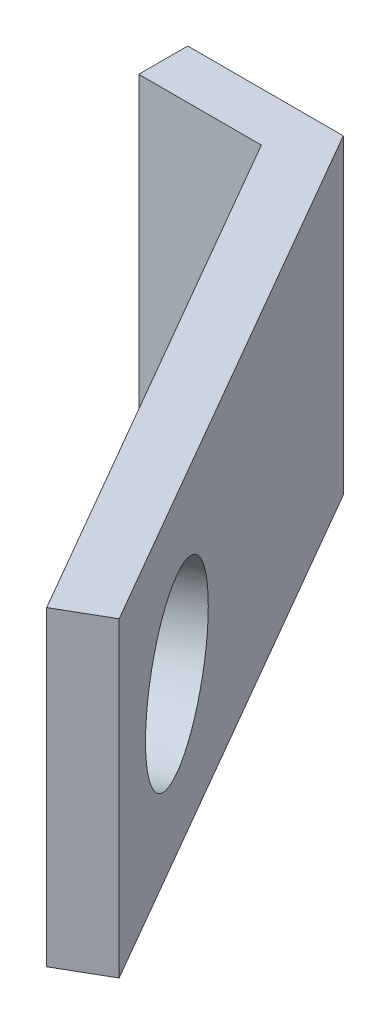
from build123d import *

# Parameters (mm, degrees)
SKETCH1_W           = 6.35
SKETCH1_H           = 12.7
BOSS_EXTRUDE1_DEPTH = 2
BOSS_EXTRUDE2_DEPTH = 12.7
SKETCH3_R           = 3.5
CUT_EXTRUDE1_DEPTH  = 13.990381057


with BuildPart() as part:
    # Sketch1 → Boss-Extrude1 (new body)
    with BuildSketch(Plane.XY):
        with Locations((3.175, 6.35)):
            Rectangle(SKETCH1_W, SKETCH1_H)
    extrude(amount=BOSS_EXTRUDE1_DEPTH)

    # Sketch2 → Boss-Extrude2 (add)
    with BuildSketch(Plane.XZ):
        Polygon((6.35, 0), (18.85, 21.650635095), (16.975, 22.733166849), (3.85, 0), align=None)
    extrude(amount=-BOSS_EXTRUDE2_DEPTH)

    # Sketch3 → Cut-Extrude1 (cut, through all)
    with BuildSketch(Plane(origin=(2.8875, 0, -1.667098902), x_dir=(0.5, 0, 0.866025404), z_dir=(-0.866025404, 0, 0.5))):
        with Locations((21.734401077, 6.35)):
            Circle(SKETCH3_R)
    extrude(amount=-CUT_EXTRUDE1_DEPTH, mode=Mode.SUBTRACT)


solid = part.part
